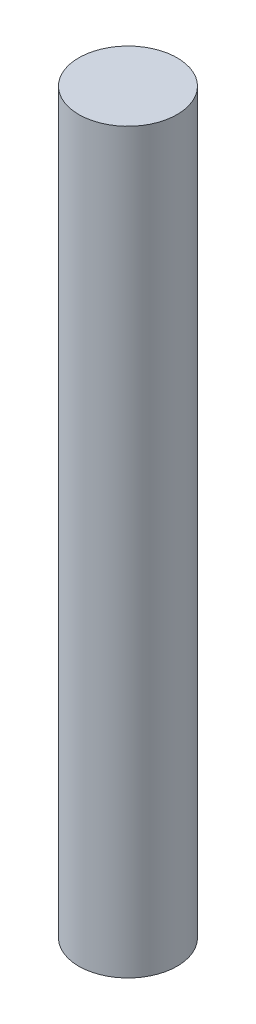
from build123d import *

# Parameters (mm, degrees)
SKETCH1_R           = 4
BOSS_EXTRUDE1_DEPTH = 60


with BuildPart() as part:
    # Sketch1 → Boss-Extrude1 (new body)
    with BuildSketch(Plane(origin=(0, 0, 0), x_dir=(1, 0, 0), z_dir=(0, 1, 0))):
        with Locations((-8.984415573, 7.071067812)):
            Circle(SKETCH1_R)
    extrude(amount=BOSS_EXTRUDE1_DEPTH)


solid = part.part
